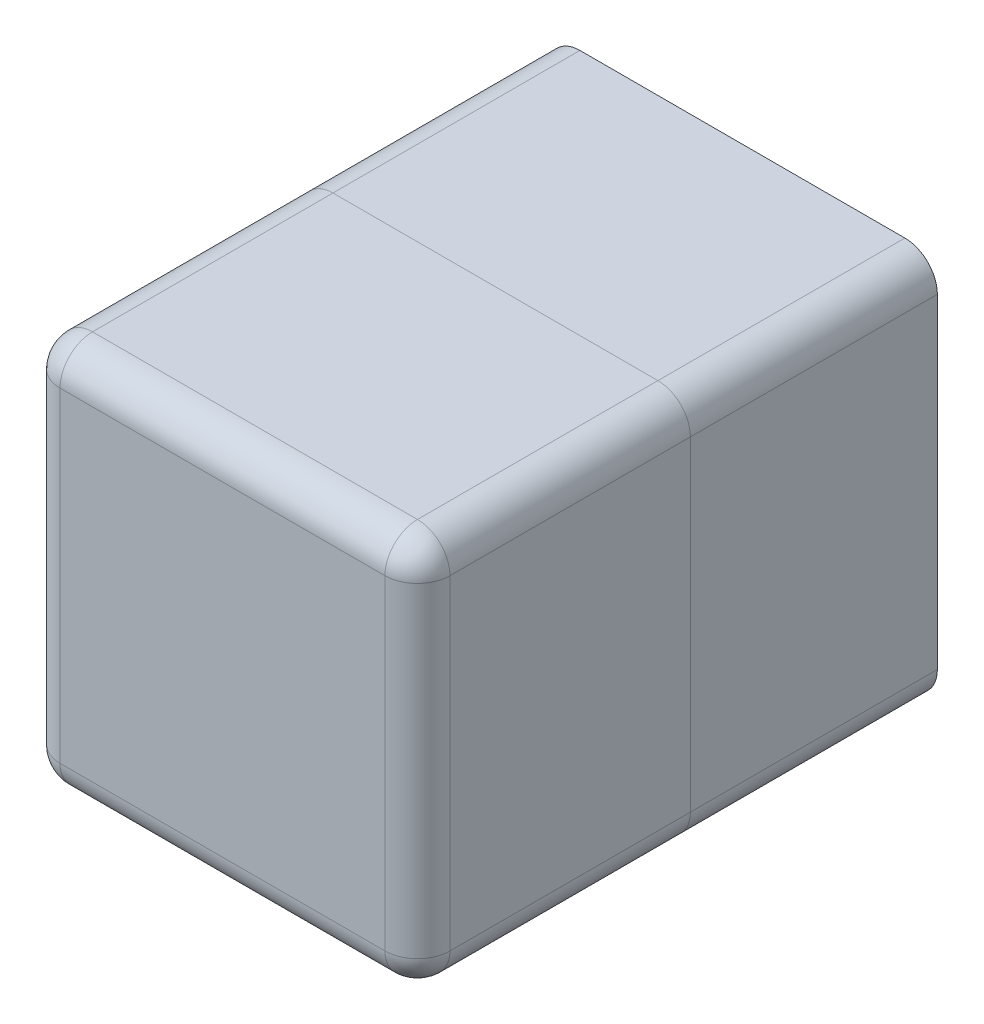
from build123d import *

# Parameters (mm, degrees)
SKETCH2_W           = 60
SKETCH2_H           = 60
BOSS_EXTRUDE1_DEPTH = 42
SKETCH3_W           = 60
SKETCH3_H           = 60
BOSS_EXTRUDE2_DEPTH = 38
FILLET1_R           = 5
FILLET2_R           = 5
FILLET3_R           = 5
SKETCH4_R           = 2.25
CUT_EXTRUDE1_DEPTH  = 10
SKETCH5_R           = 12
BOSS_EXTRUDE3_DEPTH = 4
SKETCH6_R           = 5
BOSS_EXTRUDE4_DEPTH = 28
CUT_EXTRUDE2_DEPTH  = 28
SKETCH8_R           = 5
CUT_EXTRUDE3_DEPTH  = 33


with BuildPart() as part:
    # Sketch2 → Boss-Extrude1 (new body)
    with BuildSketch(Plane.XY):
        with Locations((30, 30)):
            Rectangle(SKETCH2_W, SKETCH2_H)
    extrude(amount=BOSS_EXTRUDE1_DEPTH)

    # Fillet1
    fillet1_edges = [part.edges().sort_by_distance(p)[0] for p in [
        (0, 60, 21),
        (60, 60, 21),
        (60, 0, 21),
        (0, 0, 21),
    ]]
    fillet(fillet1_edges, radius=FILLET1_R)

    # Fillet3
    fillet3_edges = [part.edges().sort_by_distance(p)[0] for p in [
        (30, 0, 42),
        (0, 30, 42),
        (60, 30, 42),
        (30, 60, 42),
        (58.535533906, 58.535533906, 42),
        (1.464466094, 58.535533906, 42),
        (58.535533906, 1.464466094, 42),
        (1.464466094, 1.464466094, 42),
    ]]
    fillet(fillet3_edges, radius=FILLET3_R)


with BuildPart() as body_2:
    # Sketch3 → Boss-Extrude2 (new body)
    with BuildSketch(Plane(origin=(0, 0, 0), x_dir=(-1, 0, 0), z_dir=(0, 0, -1))):
        with Locations((-30, 30)):
            Rectangle(SKETCH3_W, SKETCH3_H)
    extrude(amount=BOSS_EXTRUDE2_DEPTH)

    # Fillet2
    fillet2_edges = [body_2.edges().sort_by_distance(p)[0] for p in [
        (60, 0, -19),
        (60, 60, -19),
        (0, 60, -19),
        (0, 0, -19),
    ]]
    fillet(fillet2_edges, radius=FILLET2_R)

    # Sketch4 → Cut-Extrude1 (cut)
    with BuildSketch(Plane(origin=(0, 0, -38), x_dir=(-1, 0, 0), z_dir=(0, 0, -1))):
        with Locations((-5.251262658, 54.748737342)):
            Circle(SKETCH4_R)
        with Locations((-54.748737342, 54.748737342)):
            Circle(SKETCH4_R)
        with Locations((-54.748737342, 5.251262658)):
            Circle(SKETCH4_R)
        with Locations((-5.251262658, 5.251262658)):
            Circle(SKETCH4_R)
    extrude(amount=-CUT_EXTRUDE1_DEPTH, mode=Mode.SUBTRACT)

    # Sketch5 → Boss-Extrude3 (add)
    with BuildSketch(Plane(origin=(0, 0, -38), x_dir=(-1, 0, 0), z_dir=(0, 0, -1))):
        with Locations((-30, 40)):
            Circle(SKETCH5_R)
    extrude(amount=BOSS_EXTRUDE3_DEPTH)

    # Sketch6 → Boss-Extrude4 (add)
    with BuildSketch(Plane(origin=(0, 0, -42), x_dir=(-1, 0, 0), z_dir=(0, 0, -1))):
        with Locations((-30, 40)):
            Circle(SKETCH6_R)
    extrude(amount=BOSS_EXTRUDE4_DEPTH)

    # Sketch7 → Cut-Extrude2 (cut)
    with BuildSketch(Plane(origin=(0, 42.5, 0), x_dir=(1, 0, 0), z_dir=(0, 1, 0))):
        with BuildLine():
            Line((28, 47), (28, 70))
            Line((28, 70), (32, 70))
            Line((32, 70), (32, 47))
            ThreePointArc((32, 47), (30, 45), (28, 47))
        make_face()
    extrude(amount=CUT_EXTRUDE2_DEPTH, mode=Mode.SUBTRACT)

    # Sketch8 → Cut-Extrude3 (cut)
    with BuildSketch(Plane(origin=(0, 0, -70), x_dir=(-1, 0, 0), z_dir=(0, 0, -1))):
        with Locations((-30, 40)):
            Circle(SKETCH8_R)
    extrude(amount=-CUT_EXTRUDE3_DEPTH, mode=Mode.SUBTRACT)


solid = Compound([part.part, body_2.part])
